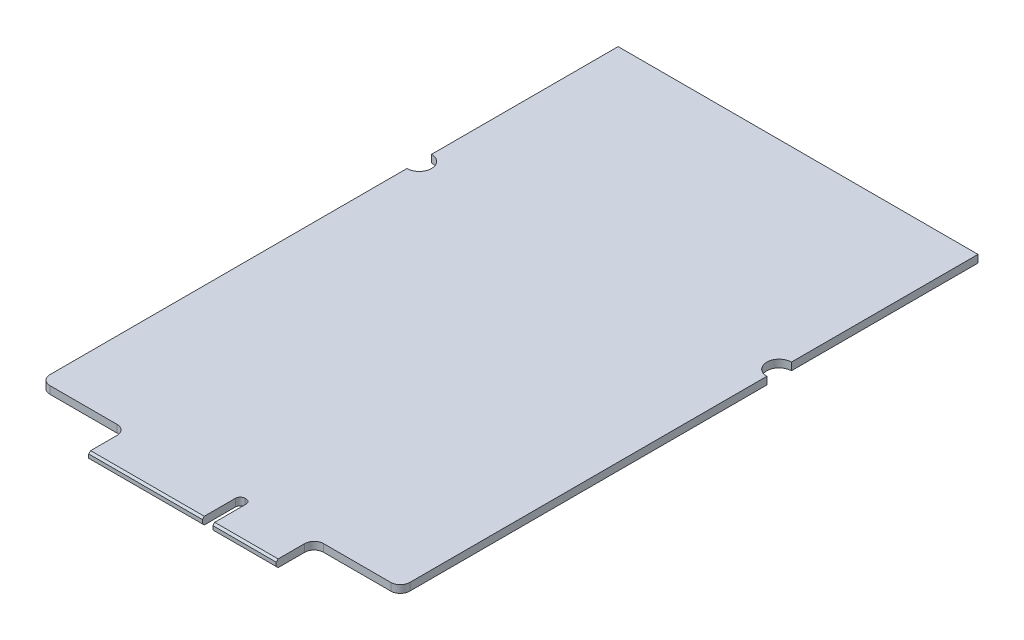
from build123d import *

# Parameters (mm, degrees)
BOSS_EXTRUDE1_DEPTH = 0.8
CHAMFER1_SIZE       = 0.2
FILLET1_R           = 1
FILLET2_R           = 0.5


with BuildPart() as part:
    # Sketch1 → Boss-Extrude1 (new body)
    with BuildSketch(Plane(origin=(0, 0, 0), x_dir=(1, 0, 0), z_dir=(0, 1, 0))):
        with BuildLine():
            Line((9.1, 0), (21.1, 0))
            Line((21.1, 0), (21.1, 4))
            Line((21.1, 4), (22.2, 4))
            Line((22.2, 4), (22.2, 0))
            Line((22.2, 0), (28.9, 0))
            Line((28.9, 0), (28.9, 4))
            Line((28.9, 4), (38, 4))
            Line((38, 4), (38, 42.7))
            ThreePointArc((38, 42.7), (36.7, 44), (38, 45.3))
            Line((38, 45.3), (38, 65))
            Line((38, 65), (0, 65))
            Line((0, 65), (0, 45.3))
            ThreePointArc((0, 45.3), (1.3, 44), (0, 42.7))
            Line((0, 42.7), (0, 4))
            Line((0, 4), (9.1, 4))
            Line((9.1, 4), (9.1, 0))
        make_face()
    extrude(amount=BOSS_EXTRUDE1_DEPTH)

    # Chamfer1
    chamfer1_edges = [part.edges().sort_by_distance(p)[0] for p in [
        (25.55, 0, 0),
        (15.1, 0, 0),
        (15.1, 0.8, 0),
        (25.55, 0.8, 0),
    ]]
    chamfer(chamfer1_edges, length=CHAMFER1_SIZE)

    # Fillet1
    fillet1_edges = [part.edges().sort_by_distance(p)[0] for p in [
        (38, 0.4, -4),
        (28.9, 0.4, -4),
        (9.1, 0.4, -4),
        (0, 0.4, -4),
    ]]
    fillet(fillet1_edges, radius=FILLET1_R)

    # Fillet2
    fillet2_edges = [part.edges().sort_by_distance(p)[0] for p in [
        (22.2, 0.4, -4),
        (21.1, 0.4, -4),
    ]]
    fillet(fillet2_edges, radius=FILLET2_R)


solid = part.part
